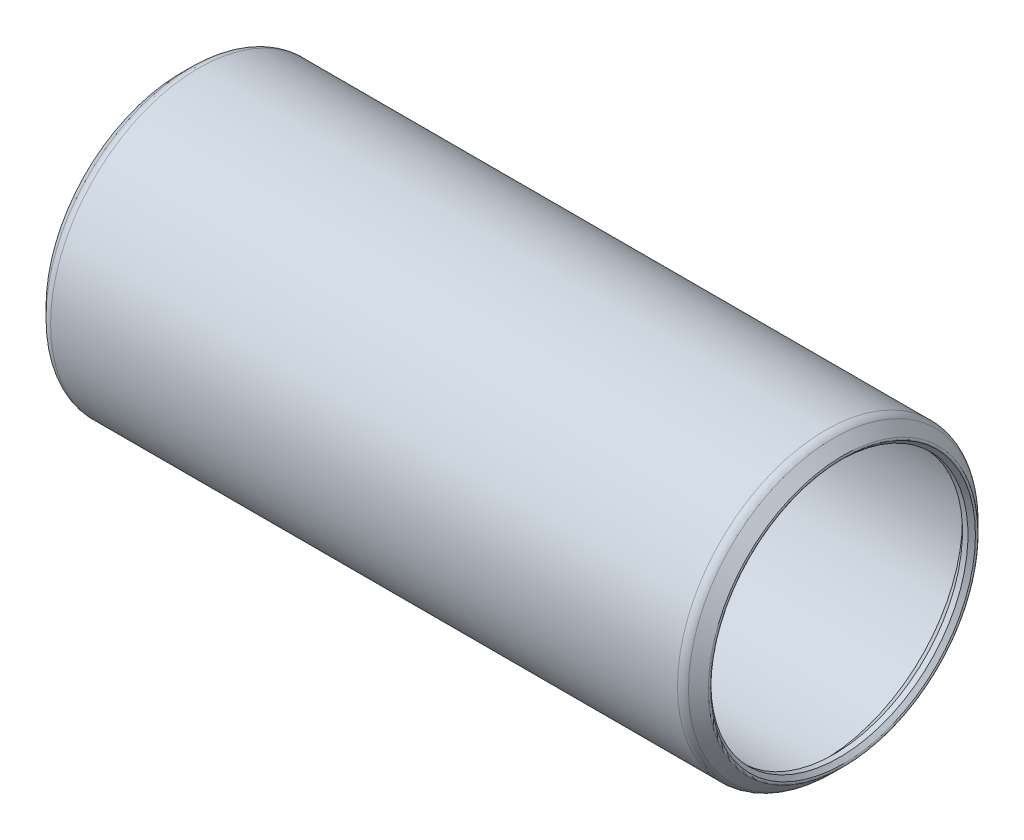
from build123d import *


with BuildPart() as part:
    # Sketch1 → Revolve1 (revolve)
    with BuildSketch(Plane.XY):
        with BuildLine():
            Line((-0.639512806, 9.167562806), (-0.381, 8.90905))
            Line((-0.381, 8.90905), (0, 8.90905))
            Line((0, 8.90905), (0.762, 9.67105))
            Line((0.762, 9.67105), (43.8531, 9.67105))
            Line((43.8531, 9.67105), (44.6151, 8.90905))
            Line((44.6151, 8.90905), (44.9961, 8.90905))
            Line((44.9961, 8.90905), (45.254612806, 9.167562806))
            ThreePointArc((45.254612806, 9.167562806), (45.291810245, 9.257365367), (45.254612806, 9.347167928))
            Line((45.254612806, 9.347167928), (44.569715367, 10.032065367))
            ThreePointArc((44.569715367, 10.032065367), (44.322504775, 10.197246204), (44.0309, 10.25525))
            Line((44.0309, 10.25525), (0.5842, 10.25525))
            ThreePointArc((0.5842, 10.25525), (0.292595225, 10.197246204), (0.045384633, 10.032065367))
            Line((0.045384633, 10.032065367), (-0.639512806, 9.347167928))
            ThreePointArc((-0.639512806, 9.347167928), (-0.676710245, 9.257365367), (-0.639512806, 9.167562806))
        make_face()
    revolve(axis=Axis((44.6151, 0, 0), (-1, 0, 0)))


solid = part.part
